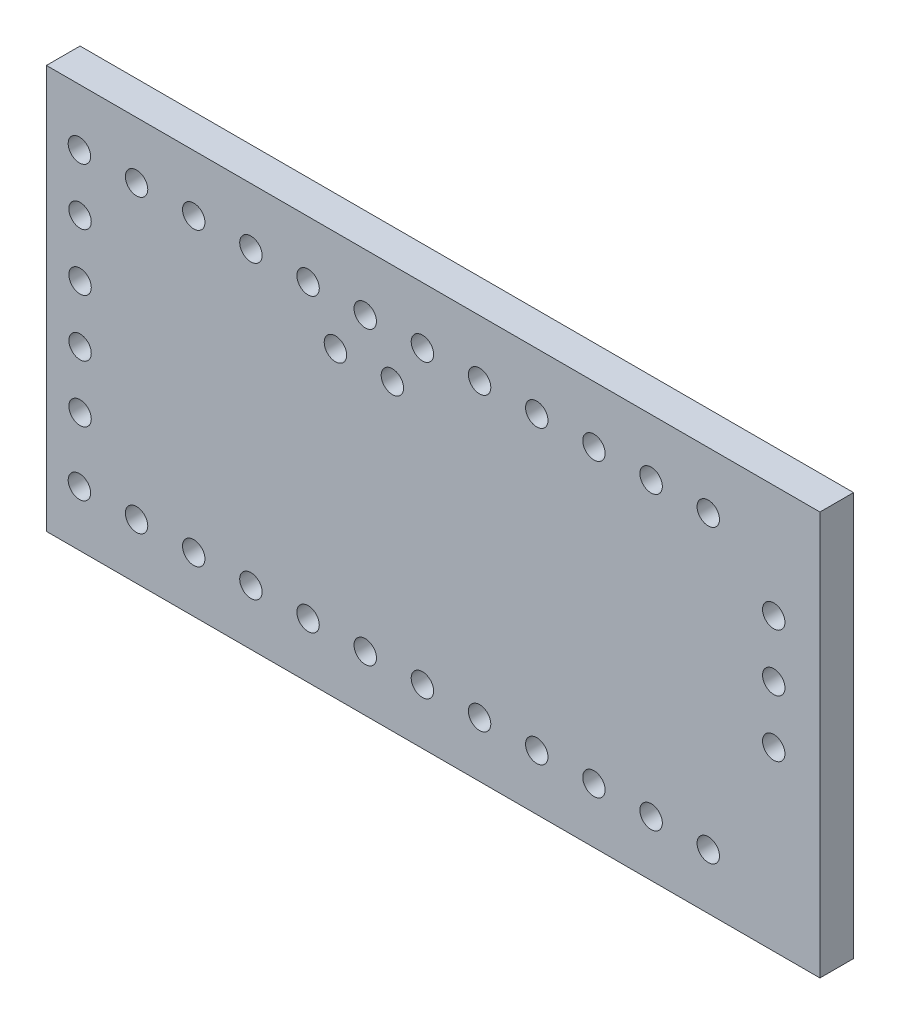
from build123d import *

# Parameters (mm, degrees)
CROQUIS2_W              = 34.5
CROQUIS2_H              = 18
SALIENTE_EXTRUIR1_DEPTH = 1.5
CROQUIS3_R              = 0.5
CORTAR_EXTRUIR1_DEPTH   = 1.5


with BuildPart() as part:
    # Croquis2 → Saliente-Extruir1 (new body)
    with BuildSketch(Plane.XY):
        with Locations((17.25, 9)):
            Rectangle(CROQUIS2_W, CROQUIS2_H)
    extrude(amount=SALIENTE_EXTRUIR1_DEPTH)

    # Croquis3 → Cortar-Extruir1 (cut)
    with BuildSketch(Plane.XY.offset(1.5)):
        with Locations((4.02, 2.47)):
            Circle(CROQUIS3_R)
        with Locations((1.47, 2.47)):
            Circle(CROQUIS3_R)
        with Locations((1.5, 12.96)):
            Circle(CROQUIS3_R)
        with Locations((1.5, 10.42)):
            Circle(CROQUIS3_R)
        with Locations((1.5, 7.88)):
            Circle(CROQUIS3_R)
        with Locations((1.5, 5.34)):
            Circle(CROQUIS3_R)
        with Locations((6.57, 2.47)):
            Circle(CROQUIS3_R)
        with Locations((9.12, 2.47)):
            Circle(CROQUIS3_R)
        with Locations((11.67, 2.47)):
            Circle(CROQUIS3_R)
        with Locations((14.22, 2.47)):
            Circle(CROQUIS3_R)
        with Locations((16.77, 2.47)):
            Circle(CROQUIS3_R)
        with Locations((19.32, 2.47)):
            Circle(CROQUIS3_R)
        with Locations((21.87, 2.47)):
            Circle(CROQUIS3_R)
        with Locations((24.42, 2.47)):
            Circle(CROQUIS3_R)
        with Locations((26.97, 2.47)):
            Circle(CROQUIS3_R)
        with Locations((29.52, 2.47)):
            Circle(CROQUIS3_R)
        with Locations((4.02, 15.47)):
            Circle(CROQUIS3_R)
        with Locations((6.57, 15.47)):
            Circle(CROQUIS3_R)
        with Locations((9.12, 15.47)):
            Circle(CROQUIS3_R)
        with Locations((11.67, 15.47)):
            Circle(CROQUIS3_R)
        with Locations((14.22, 15.47)):
            Circle(CROQUIS3_R)
        with Locations((16.77, 15.47)):
            Circle(CROQUIS3_R)
        with Locations((19.32, 15.47)):
            Circle(CROQUIS3_R)
        with Locations((21.87, 15.47)):
            Circle(CROQUIS3_R)
        with Locations((24.42, 15.47)):
            Circle(CROQUIS3_R)
        with Locations((26.97, 15.47)):
            Circle(CROQUIS3_R)
        with Locations((29.52, 15.47)):
            Circle(CROQUIS3_R)
        with Locations((1.47, 15.47)):
            Circle(CROQUIS3_R)
        with Locations((32.44, 12.96)):
            Circle(CROQUIS3_R)
        with Locations((32.44, 10.42)):
            Circle(CROQUIS3_R)
        with Locations((32.44, 7.88)):
            Circle(CROQUIS3_R)
        with Locations((15.43, 13.5)):
            Circle(CROQUIS3_R)
        with Locations((12.89, 13.5)):
            Circle(CROQUIS3_R)
    extrude(amount=-CORTAR_EXTRUIR1_DEPTH, mode=Mode.SUBTRACT)


solid = part.part
